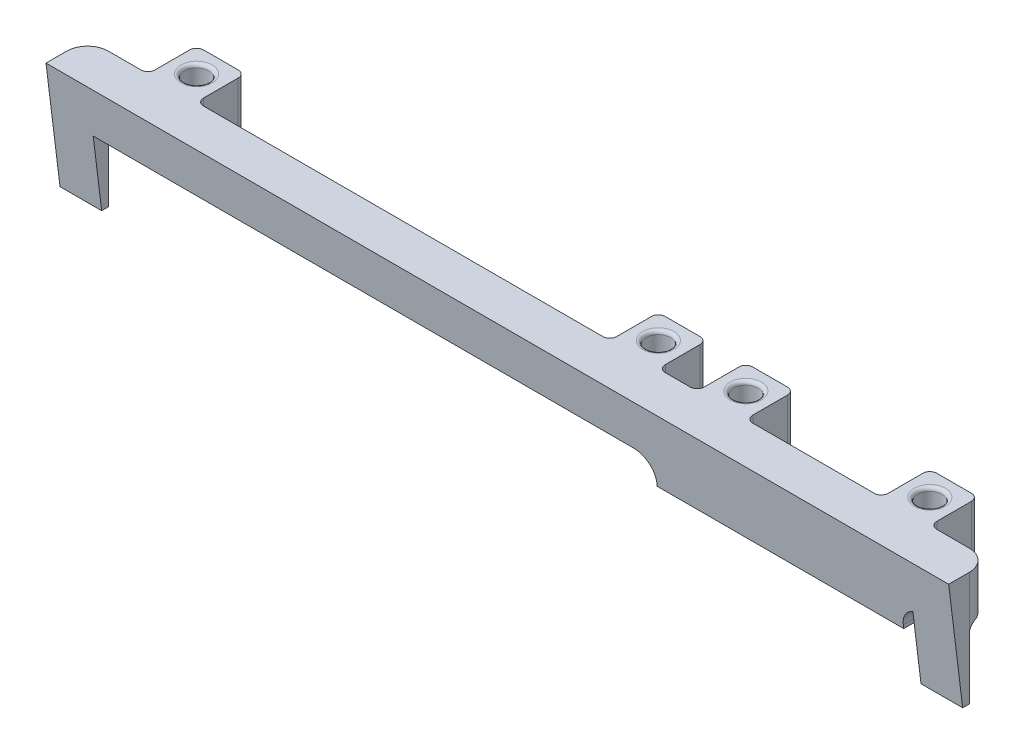
from build123d import *

# Parameters (mm, degrees)
SKETCH1_R           = 1.75
BOSS_EXTRUDE1_DEPTH = 6.5
SKETCH3_R           = 1.75
BOSS_EXTRUDE2_DEPTH = 3.5
FILLET1_R           = 3
FILLET2_R           = 0.5
CUT_EXTRUDE1_DEPTH  = 176.5
BOSS_EXTRUDE3_DEPTH = 6
FILLET3_R           = 1
BOSS_EXTRUDE4_DEPTH = 6
FILLET4_R           = 1


with BuildPart() as part:
    # Sketch1 → Boss-Extrude1 (new body)
    with BuildSketch(Plane(origin=(0, 0, 0), x_dir=(1, 0, 0), z_dir=(0, 1, 0))):
        with BuildLine():
            Line((0, 0), (130, 0))
            Line((130, 0), (130, 3))
            ThreePointArc((130, 3), (129.121320344, 5.121320344), (127, 6))
            Line((127, 6), (122.3, 6))
            ThreePointArc((122.3, 6), (121.592893219, 6.292893219), (121.3, 7))
            Line((121.3, 7), (121.3, 12))
            ThreePointArc((121.3, 12), (121.007106781, 12.707106781), (120.3, 13))
            Line((120.3, 13), (115.3, 13))
            ThreePointArc((115.3, 13), (114.592893219, 12.707106781), (114.3, 12))
            Line((114.3, 12), (114.3, 7))
            ThreePointArc((114.3, 7), (114.007106781, 6.292893219), (113.3, 6))
            Line((113.3, 6), (95.8, 6))
            ThreePointArc((95.8, 6), (95.092893219, 6.292893219), (94.8, 7))
            Line((94.8, 7), (94.8, 12))
            ThreePointArc((94.8, 12), (94.507106781, 12.707106781), (93.8, 13))
            Line((93.8, 13), (88.8, 13))
            ThreePointArc((88.8, 13), (88.092893219, 12.707106781), (87.8, 12))
            Line((87.8, 12), (87.8, 7))
            ThreePointArc((87.8, 7), (87.507106781, 6.292893219), (86.8, 6))
            Line((86.8, 6), (83.200000395, 6))
            ThreePointArc((83.200000395, 6), (82.492893614, 6.292893219), (82.200000395, 7))
            Line((82.200000395, 7), (82.200000395, 12))
            ThreePointArc((82.200000395, 12), (81.907107176, 12.707106781), (81.200000395, 13))
            Line((81.200000395, 13), (76.2, 13))
            ThreePointArc((76.2, 13), (75.492893219, 12.707106781), (75.2, 12))
            Line((75.2, 12), (75.2, 7))
            ThreePointArc((75.2, 7), (74.907106781, 6.292893219), (74.2, 6))
            Line((74.2, 6), (16.7, 6))
            ThreePointArc((16.7, 6), (15.992893219, 6.292893219), (15.7, 7))
            Line((15.7, 7), (15.7, 12))
            ThreePointArc((15.7, 12), (15.407106781, 12.707106781), (14.7, 13))
            Line((14.7, 13), (9.7, 13))
            ThreePointArc((9.7, 13), (8.992893219, 12.707106781), (8.7, 12))
            Line((8.7, 12), (8.7, 7))
            ThreePointArc((8.7, 7), (8.407106781, 6.292893219), (7.7, 6))
            Line((7.7, 6), (3, 6))
            ThreePointArc((3, 6), (0.878679656, 5.121320344), (0, 3))
            Line((0, 3), (0, 0))
        make_face()
        with Locations((78.7, 9.5)):
            Circle(SKETCH1_R, mode=Mode.SUBTRACT)
        with Locations((12.2, 9.5)):
            Circle(SKETCH1_R, mode=Mode.SUBTRACT)
        with Locations((91.3, 9.5)):
            Circle(SKETCH1_R, mode=Mode.SUBTRACT)
        with Locations((117.8, 9.5)):
            Circle(SKETCH1_R, mode=Mode.SUBTRACT)
    extrude(amount=BOSS_EXTRUDE1_DEPTH)

    # Sketch3 → Boss-Extrude2 (add)
    with BuildSketch(Plane.XZ):
        with BuildLine():
            Line((121.3, -12), (121.3, -7))
            ThreePointArc((121.3, -7), (121.592893219, -6.292893219), (122.3, -6))
            Line((122.3, -6), (122.3, 0))
            Line((122.3, 0), (86.8, 0))
            Line((86.8, 0), (86.8, -6))
            ThreePointArc((86.8, -6), (87.507106781, -6.292893219), (87.8, -7))
            Line((87.8, -7), (87.8, -12))
            ThreePointArc((87.8, -12), (88.092893219, -12.707106781), (88.8, -13))
            Line((88.8, -13), (93.8, -13))
            ThreePointArc((93.8, -13), (94.507106781, -12.707106781), (94.8, -12))
            Line((94.8, -12), (94.8, -7))
            ThreePointArc((94.8, -7), (95.092893219, -6.292893219), (95.8, -6))
            Line((95.8, -6), (113.3, -6))
            ThreePointArc((113.3, -6), (114.007106781, -6.292893219), (114.3, -7))
            Line((114.3, -7), (114.3, -12))
            ThreePointArc((114.3, -12), (114.592893219, -12.707106781), (115.3, -13))
            Line((115.3, -13), (120.3, -13))
            ThreePointArc((120.3, -13), (121.007106781, -12.707106781), (121.3, -12))
        make_face()
        with Locations((91.3, -9.5)):
            Circle(SKETCH3_R, mode=Mode.SUBTRACT)
        with Locations((117.8, -9.5)):
            Circle(SKETCH3_R, mode=Mode.SUBTRACT)
    extrude(amount=BOSS_EXTRUDE2_DEPTH)

    # Fillet1
    fillet1_edges = [part.edges().sort_by_distance(p)[0] for p in [
        (86.8, 0, -3),
        (122.3, 0, -3),
    ]]
    fillet(fillet1_edges, radius=FILLET1_R)

    # Fillet2
    fillet2_edges = [part.edges().sort_by_distance(p)[0] for p in [
        (89.55, -3.5, -9.5),
        (116.05, -3.5, -9.5),
        (76.95, 0, -9.5),
        (76.95, 6.5, -9.5),
        (10.45, 0, -9.5),
        (10.45, 6.5, -9.5),
        (89.55, 6.5, -9.5),
        (116.05, 6.5, -9.5),
    ]]
    fillet(fillet2_edges, radius=FILLET2_R)

    # Sketch5 → Cut-Extrude1 (cut)
    with BuildSketch(Plane.ZY):
        Polygon((0, 6.61525709), (0, -3.5), (0, -7.169665504), (-1.692575668, -7.169665504), align=None)
    extrude(amount=-CUT_EXTRUDE1_DEPTH, mode=Mode.SUBTRACT)

    # Sketch6 → Boss-Extrude3 (add)
    with BuildSketch(Plane.ZY):
        Polygon((-0.812251437, 0), (-2.030944871, -9.925461516), (-3.030948804, -9.925461516), (-3.030948804, -3.5), (-3, 6.5), (-0.014151791, 6.5), align=None)
    extrude(amount=-BOSS_EXTRUDE3_DEPTH)

    # Fillet3
    fillet3_edges = [part.edges().sort_by_distance(p)[0] for p in [
        (3.000033724, 0, -3.020116723),
    ]]
    fillet(fillet3_edges, radius=FILLET3_R)

    # Sketch7 → Boss-Extrude4 (add)
    with BuildSketch(Plane(origin=(130, 0, 0), x_dir=(0, 0, -1), z_dir=(1, 0, 0))):
        Polygon((0.014151791, 6.5), (2.030944871, -9.925461516), (3.030948804, -9.925461516), (3, 6.5), align=None)
    extrude(amount=-BOSS_EXTRUDE4_DEPTH)

    # Fillet4
    fillet4_edges = [part.edges().sort_by_distance(p)[0] for p in [
        (124.633330424, -0.075012534, -3.012388618),
        (127.6499875, 0, -3.01224728),
    ]]
    fillet(fillet4_edges, radius=FILLET4_R)


solid = part.part
